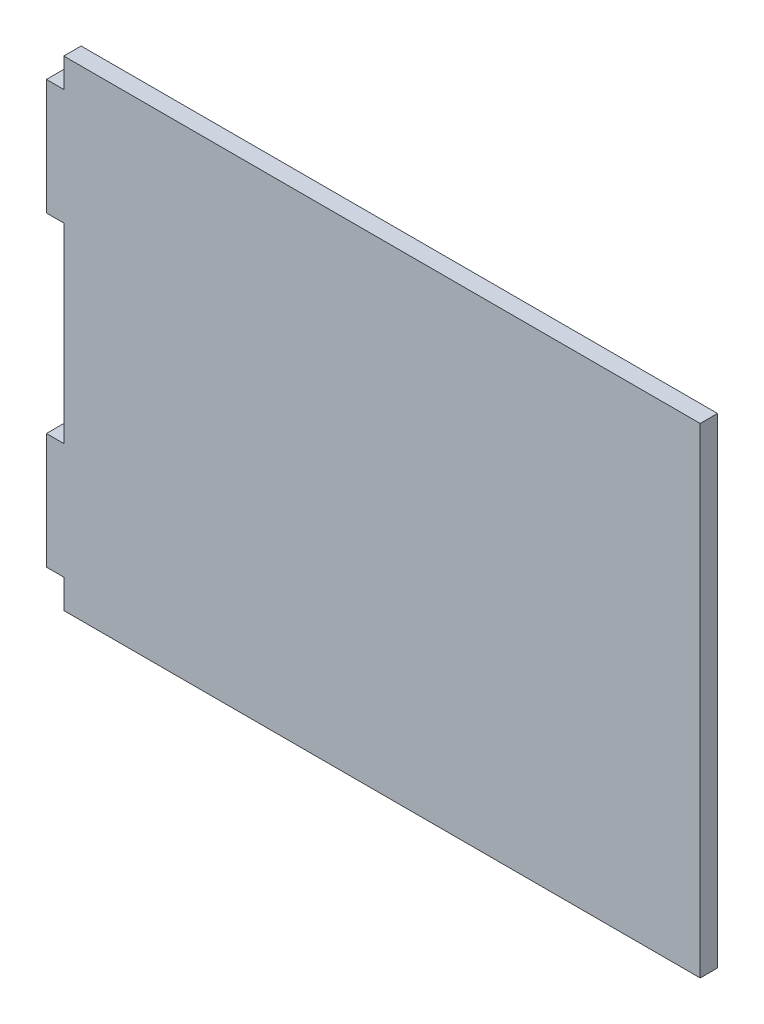
from build123d import *

# Parameters (mm, degrees)
RESSALTO_EXTRUS_O1_DEPTH = 3


with BuildPart() as part:
    # Esboço1 → Ressalto-extrusão1 (new body)
    with BuildSketch(Plane.XY):
        Polygon((-55.36120607, 7.239336493), (-55.36120607, -25.760663507), (-58.36120607, -25.760663507), (-58.36120607, -45.760663507), (-55.36120607, -45.760663507), (-55.36120607, -50.760663507), (54.63879393, -50.760663507), (54.63879393, 32.239336493), (-55.36120607, 32.239336493), (-55.36120607, 27.239336493), (-58.36120607, 27.239336493), (-58.36120607, 7.239336493), align=None)
    extrude(amount=RESSALTO_EXTRUS_O1_DEPTH)


solid = part.part
